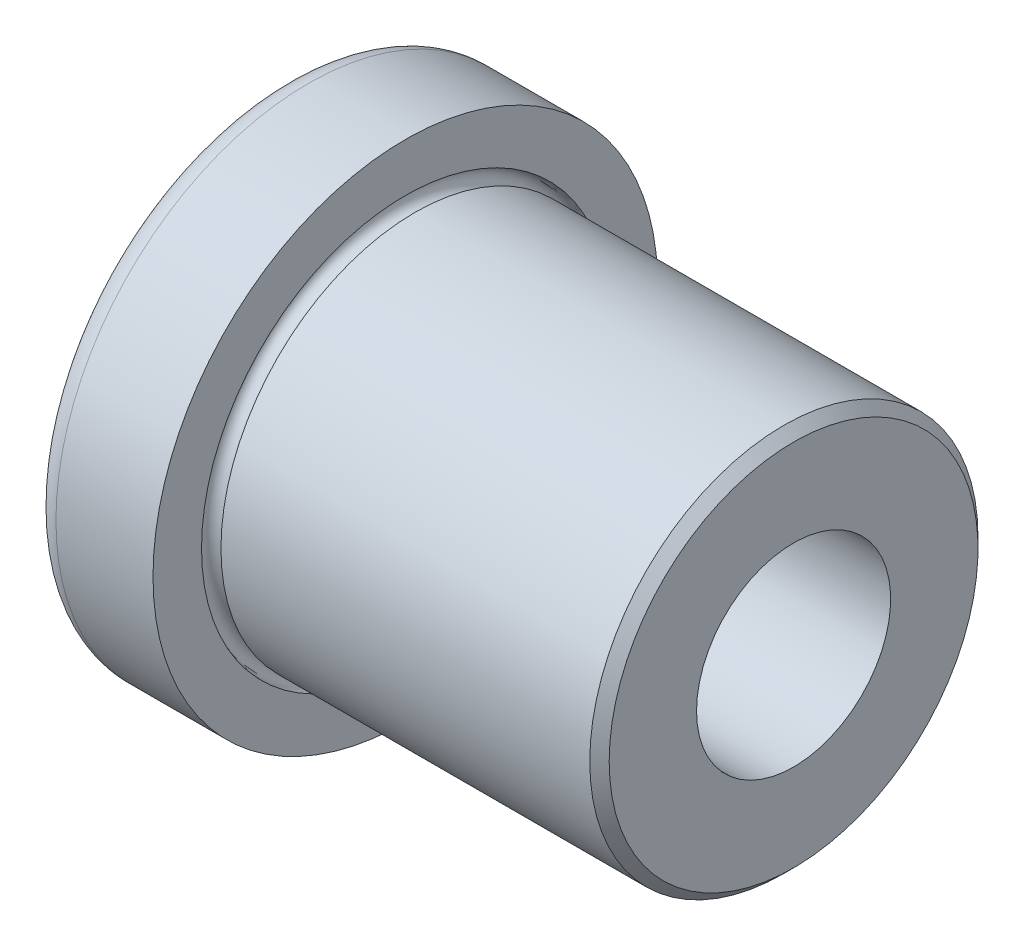
from build123d import *


with BuildPart() as part:
    # Sketch1 → BaseBody (revolve)
    with BuildSketch(Plane.XY):
        with BuildLine():
            Line((0, 3.9624), (0, 7.4676))
            ThreePointArc((0, 7.4676), (0.23062412, 8.02437588), (0.7874, 8.255))
            Line((0.7874, 8.255), (3.9624, 8.255))
            Line((3.9624, 8.255), (3.9624, 6.6675))
            ThreePointArc((3.9624, 6.6675), (3.737893597, 6.125493597), (4.2799, 6.35))
            Line((4.2799, 6.35), (16.3449, 6.35))
            Line((16.3449, 6.35), (16.6624, 6.0325))
            Line((16.6624, 6.0325), (16.6624, 3.175))
            Line((16.6624, 3.175), (0.7874, 3.175))
            ThreePointArc((0.7874, 3.175), (0.23062412, 3.40562412), (0, 3.9624))
        make_face()
    revolve(axis=Axis((0, 0, 0), (1, 0, 0)))


solid = part.part
